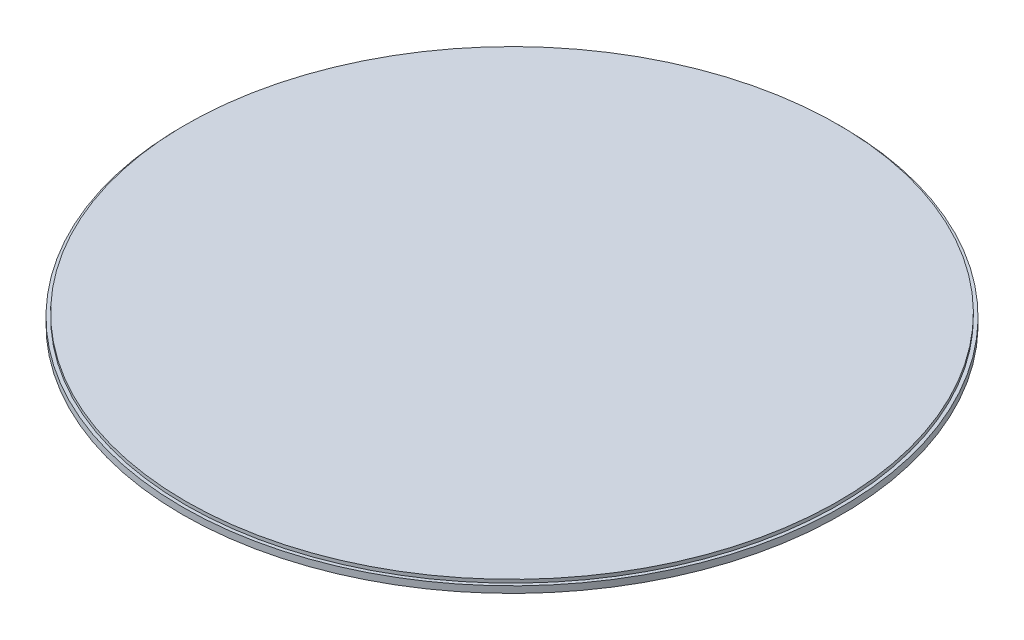
from build123d import *

# Parameters (mm, degrees)
SKETCH1_R           = 100
SKETCH1_R_2         = 99
BOSS_EXTRUDE1_DEPTH = 2
SKETCH1_3_R         = 99
BOSS_EXTRUDE2_DEPTH = 3


with BuildPart() as part:
    # Sketch1 → Boss-Extrude1 (new body)
    with BuildSketch(Plane(origin=(0, 0, 0), x_dir=(1, 0, 0), z_dir=(0, 1, 0))):
        Circle(SKETCH1_R)
        Circle(SKETCH1_R_2, mode=Mode.SUBTRACT)
    extrude(amount=BOSS_EXTRUDE1_DEPTH)

    # Sketch1_3 → Boss-Extrude2 (add)
    with BuildSketch(Plane(origin=(0, 0, 0), x_dir=(1, 0, 0), z_dir=(0, 1, 0))):
        Circle(SKETCH1_3_R)
    extrude(amount=BOSS_EXTRUDE2_DEPTH)


solid = part.part
